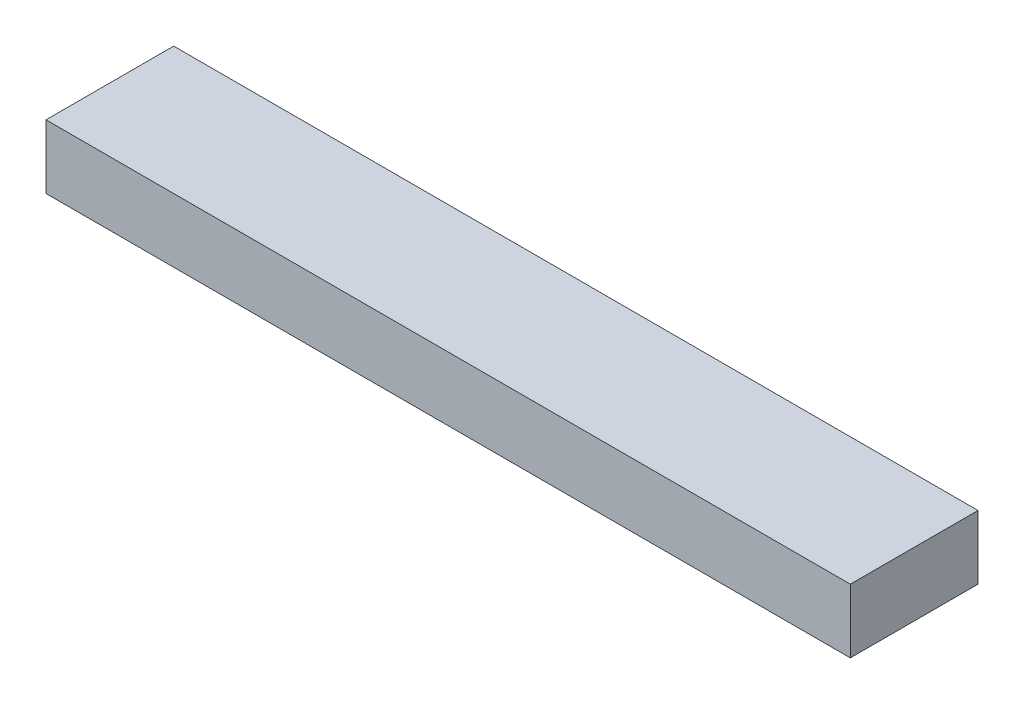
from build123d import *

# Parameters (mm, degrees)
SKETCH1_W           = 50.8
SKETCH1_H           = 25.4
BOSS_EXTRUDE1_DEPTH = 320


with BuildPart() as part:
    # Sketch1 → Boss-Extrude1 (new body)
    with BuildSketch(Plane(origin=(0, 0, 0), x_dir=(0, 0, -1), z_dir=(1, 0, 0))):
        with Locations((25.4, 12.7)):
            Rectangle(SKETCH1_W, SKETCH1_H)
    extrude(amount=BOSS_EXTRUDE1_DEPTH)


solid = part.part
